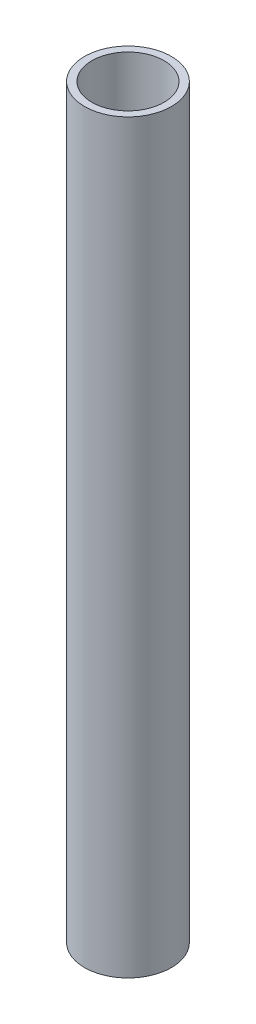
from build123d import *

# Parameters (mm, degrees)
SKETCH1_R           = 21.082
SKETCH1_R_2         = 17.526
BOSS_EXTRUDE1_DEPTH = 361.95


with BuildPart() as part:
    # Sketch1 → Boss-Extrude1 (new body)
    with BuildSketch(Plane(origin=(0, 0, 0), x_dir=(1, 0, 0), z_dir=(0, 1, 0))):
        Circle(SKETCH1_R)
        Circle(SKETCH1_R_2, mode=Mode.SUBTRACT)
    extrude(amount=BOSS_EXTRUDE1_DEPTH)


solid = part.part
